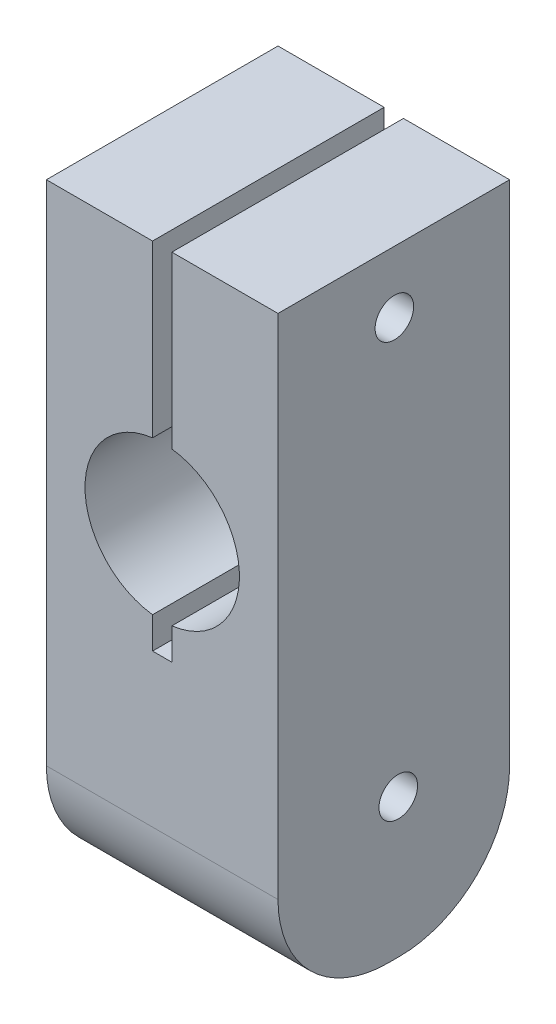
from build123d import *

# Parameters (mm, degrees)
SKETCH1_W           = 19.05
SKETCH1_H           = 19.05
BOSS_EXTRUDE1_DEPTH = 50.8
SKETCH4_W           = 1.5875
SKETCH4_H           = 19.05
CUT_EXTRUDE1_DEPTH  = 29.21
CUT_EXTRUDE2_START  = -19.05
SKETCH5_R           = 6.35
CUT_EXTRUDE2_DEPTH  = 19.05
FILLET3_R           = 9.05
SKETCH6_R           = 1.5875
CUT_EXTRUDE3_DEPTH  = 19.05


with BuildPart() as part:
    # Sketch1 → Boss-Extrude1 (new body)
    with BuildSketch(Plane(origin=(0, 0, 0), x_dir=(1, 0, 0), z_dir=(0, 1, 0))):
        Rectangle(SKETCH1_W, SKETCH1_H)
    extrude(amount=BOSS_EXTRUDE1_DEPTH)

    # Sketch4 → Cut-Extrude1 (cut)
    with BuildSketch(Plane(origin=(0, 50.8, 0), x_dir=(1, 0, 0), z_dir=(0, 1, 0))):
        Rectangle(SKETCH4_W, SKETCH4_H)
    extrude(amount=-CUT_EXTRUDE1_DEPTH, mode=Mode.SUBTRACT)

    # Sketch5 → Cut-Extrude2 (cut)
    with BuildSketch(Plane.XY.offset(9.525).offset(CUT_EXTRUDE2_START)):
        with Locations((0, 30.48)):
            Circle(SKETCH5_R)
    extrude(amount=CUT_EXTRUDE2_DEPTH, mode=Mode.SUBTRACT)

    # Fillet3
    fillet3_edges = [part.edges().sort_by_distance(p)[0] for p in [
        (0, 0, 9.525),
        (0, 0, -9.525),
    ]]
    fillet(fillet3_edges, radius=FILLET3_R)

    # Sketch6 → Cut-Extrude3 (cut)
    with BuildSketch(Plane(origin=(9.525, 0, 0), x_dir=(0, 0, -1), z_dir=(1, 0, 0))):
        with Locations((0.047497924, 45.720222057)):
            Circle(SKETCH6_R)
        with Locations((0.368108908, 11.431720944)):
            Circle(SKETCH6_R)
    extrude(amount=-CUT_EXTRUDE3_DEPTH, mode=Mode.SUBTRACT)


solid = part.part
